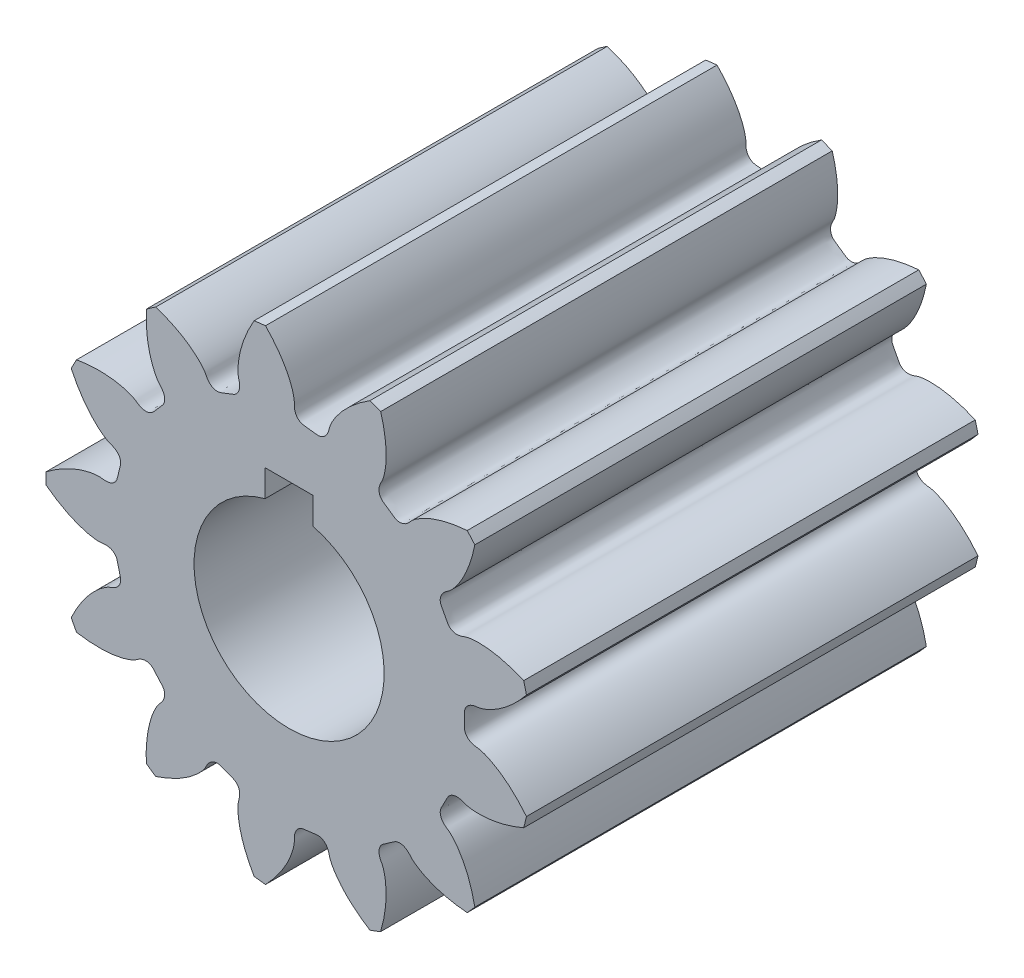
from build123d import *

# Parameters (mm, degrees)
BOSS_EXTRUDE1_DEPTH = 19.000000285


with BuildPart() as part:
    # Sketch1 → Boss-Extrude1 (new body)
    with BuildSketch(Plane.XY.offset(9.500000143)):
        with BuildLine():
            ThreePointArc((7.814726575, 6.600521756), (7.656677444, 6.783224114), (7.494357911, 6.962143228))
            add(Edge.make_bspline(
                [(3.852181327, 9.476156246), (3.919123652, 9.24993203), (3.98995363, 8.951615997), (4.045080446, 8.583763832), (4.066554173, 8.387248685), (4.079293934, 8.20275644), (4.084294989, 8.030651545), (4.082567712, 7.871237234), (4.07513333, 7.724756024), (4.063021014, 7.591389048), (4.047264207, 7.471256099), (4.028898477, 7.364414951), (4.008954757, 7.270863467), (3.988466837, 7.190533767), (3.968435849, 7.12331107), (3.949920357, 7.068981115), (3.933776349, 7.027377348), (3.910138888, 6.971704064), (3.877939068, 6.920721978), (3.850301468, 6.863364511), (3.833117776, 6.824070139), (3.818014359, 6.784105635), (3.804950881, 6.742844207), (3.79415029, 6.699282969), (3.786099872, 6.651977335), (3.781908634, 6.598855696), (3.783931909, 6.537201836), (3.79681493, 6.464228083), (3.828598855, 6.379850161), (3.886730558, 6.292619147), (4.013194901, 6.189835632), (4.1990099, 6.083315837), (4.364498543, 5.947348232), (4.505447672, 5.865549552), (4.607623873, 5.842128007), (4.697789335, 5.842330344), (4.770589362, 5.856161358), (4.828954186, 5.876132322), (4.877137548, 5.898888389), (4.918514367, 5.92319047), (4.95541489, 5.948736225), (4.989362623, 5.975582293), (5.021374338, 6.003875841), (5.052021794, 6.033876848), (5.09585153, 6.08005769), (5.132102395, 6.128243541), (5.175775862, 6.170086969), (5.208951315, 6.199934778), (5.253185023, 6.23651273), (5.308936251, 6.279079526), (5.376780709, 6.326721367), (5.457180727, 6.37854288), (5.550566359, 6.433601529), (5.657305178, 6.490934128), (5.777710381, 6.54955192), (5.912036424, 6.608446138), (6.060478894, 6.666590262), (6.223173166, 6.722943429), (6.400193993, 6.776453395), (6.591553537, 6.82606034), (6.955049526, 6.90495804), (7.259096519, 6.94451518), (7.494357911, 6.962143228)],
                knots=[0, 0, 0, 0, 0.096898989, 0.125710726, 0.152776298, 0.178095703, 0.201668943, 0.223496017, 0.243576925, 0.261911668, 0.278500244, 0.293342655, 0.3064389, 0.31778898, 0.327392894, 0.335250642, 0.341362226, 0.345727644, 0.360077399, 0.366027323, 0.371876298, 0.377692643, 0.383571459, 0.389647833, 0.396117153, 0.403264993, 0.41150466, 0.421398561, 0.433571282, 0.448324753, 0.463840247, 0.5, 0.536159753, 0.551675247, 0.566428718, 0.578601439, 0.58849534, 0.596735007, 0.603882847, 0.610352167, 0.616428541, 0.622307357, 0.628123702, 0.633972677, 0.639922601, 0.654272356, 0.658637774, 0.664749358, 0.672607106, 0.68221102, 0.6935611, 0.706657345, 0.721499756, 0.738088332, 0.756423075, 0.776503983, 0.798331057, 0.821904297, 0.847223702, 0.874289274, 0.903101011, 1.000000005, 1.000000005, 1.000000005, 1.000000005], degree=3))
            ThreePointArc((3.852181327, 9.476156246), (3.627329752, 9.564482056), (3.400455086, 9.647473416))
            add(Edge.make_bspline(
                [(-0.992852221, 10.180917536), (-0.828446101, 10.011715591), (-0.627094897, 9.780486193), (-0.4073331, 9.480387986), (-0.296993917, 9.316361804), (-0.199975598, 9.158922496), (-0.115566251, 9.008855286), (-0.043012155, 8.866898217), (0.01847824, 8.733740619), (0.06973204, 8.610021152), (0.111608646, 8.496326155), (0.144998157, 8.393188036), (0.170814413, 8.301084003), (0.190004333, 8.220434374), (0.203507719, 8.151602768), (0.212361454, 8.094891403), (0.217400879, 8.050550603), (0.222343612, 7.990269482), (0.217524644, 7.930163084), (0.219708109, 7.866531736), (0.22275371, 7.823752638), (0.22795273, 7.781346919), (0.235560737, 7.738740838), (0.246241205, 7.695149993), (0.261096938, 7.649521718), (0.282072637, 7.600537077), (0.312516136, 7.546885558), (0.357836078, 7.488257548), (0.425191722, 7.428315334), (0.517203063, 7.378091257), (0.676947558, 7.345851885), (0.890980785, 7.337885826), (1.100700998, 7.294398899), (1.263518996, 7.287472091), (1.364876063, 7.314216991), (1.444619585, 7.356298131), (1.502653214, 7.402376745), (1.54505173, 7.447183641), (1.577140706, 7.489725063), (1.60248432, 7.530472253), (1.623286406, 7.570240424), (1.640869641, 7.609787735), (1.65606594, 7.649717014), (1.669260751, 7.690524168), (1.686608747, 7.751783967), (1.696314213, 7.811297037), (1.715539536, 7.868643625), (1.731043973, 7.910489948), (1.753212354, 7.963434545), (1.782795839, 8.027034459), (1.820728855, 8.100748106), (1.867836877, 8.183997528), (1.924938718, 8.276148008), (1.992807461, 8.376517506), (2.072179927, 8.484376071), (2.163750223, 8.598948736), (2.268168582, 8.719417456), (2.386038583, 8.844923506), (2.51791542, 8.974569907), (2.664302384, 9.10742389), (2.949496508, 9.346209343), (3.200333631, 9.522533134), (3.400455086, 9.647473416)],
                knots=[0, 0, 0, 0, 0.096898989, 0.125710726, 0.152776298, 0.178095703, 0.201668943, 0.223496017, 0.243576925, 0.261911668, 0.278500244, 0.293342655, 0.3064389, 0.31778898, 0.327392894, 0.335250642, 0.341362226, 0.345727644, 0.360077399, 0.366027323, 0.371876298, 0.377692643, 0.383571459, 0.389647833, 0.396117153, 0.403264993, 0.41150466, 0.421398561, 0.433571282, 0.448324753, 0.463840247, 0.5, 0.536159753, 0.551675247, 0.566428718, 0.578601439, 0.58849534, 0.596735007, 0.603882847, 0.610352167, 0.616428541, 0.622307357, 0.628123702, 0.633972677, 0.639922601, 0.654272356, 0.658637774, 0.664749358, 0.672607106, 0.68221102, 0.6935611, 0.706657345, 0.721499756, 0.738088332, 0.756423075, 0.776503983, 0.798331057, 0.821904297, 0.847223702, 0.874289274, 0.903101011, 1.000000005, 1.000000005, 1.000000005, 1.000000005], degree=3))
            ThreePointArc((-0.992852221, 10.180917536), (-1.232995454, 10.15463242), (-1.472451002, 10.122683705))
            add(Edge.make_bspline(
                [(-5.610435273, 8.553353308), (-5.386228819, 8.479935759), (-5.100483523, 8.368764866), (-4.766431525, 8.2051695), (-4.592504263, 8.111208703), (-4.433433113, 8.016889781), (-4.288952638, 7.923238844), (-4.158738437, 7.831259673), (-4.042409975, 7.741930486), (-3.939531686, 7.656201167), (-3.849615093, 7.574990276), (-3.772119476, 7.499182886), (-3.706457438, 7.429626227), (-3.651985856, 7.367132529), (-3.608041559, 7.312460504), (-3.573846881, 7.266359621), (-3.548778494, 7.22943973), (-3.516387888, 7.17836045), (-3.492722036, 7.122899392), (-3.461217713, 7.067571338), (-3.438640528, 7.03110769), (-3.414330105, 6.995975395), (-3.387793516, 6.961785201), (-3.358078755, 6.928150885), (-3.323720141, 6.894652858), (-3.282382783, 6.861027006), (-3.2304933, 6.827668745), (-3.163118689, 6.796817447), (-3.075621693, 6.775042981), (-2.970809404, 6.773331572), (-2.814380295, 6.819021994), (-2.621161272, 6.911434599), (-2.415253863, 6.97039068), (-2.267866638, 7.039922592), (-2.190548387, 7.110707003), (-2.139495086, 7.185026664), (-2.109522659, 7.252796823), (-2.092803441, 7.312174932), (-2.084160048, 7.364755982), (-2.080655556, 7.412613591), (-2.080717414, 7.457493769), (-2.083526784, 7.50068251), (-2.088627191, 7.543100203), (-2.095907796, 7.585365079), (-2.109015757, 7.647669953), (-2.128079096, 7.704876514), (-2.137706205, 7.764588848), (-2.143424664, 7.808847199), (-2.14840012, 7.866029472), (-2.151761598, 7.936092529), (-2.15243002, 8.018991074), (-2.149405874, 8.114596966), (-2.141669168, 8.222728712), (-2.128218412, 8.343141666), (-2.108061958, 8.475531907), (-2.080225059, 8.619535802), (-2.043751801, 8.774731187), (-1.997708668, 8.940638196), (-1.941187215, 9.116720605), (-1.873308319, 9.302386379), (-1.731750597, 9.646356716), (-1.591587106, 9.919053502), (-1.472451002, 10.122683705)],
                knots=[0, 0, 0, 0, 0.096898989, 0.125710726, 0.152776298, 0.178095703, 0.201668943, 0.223496017, 0.243576925, 0.261911668, 0.278500244, 0.293342655, 0.3064389, 0.31778898, 0.327392894, 0.335250642, 0.341362226, 0.345727644, 0.360077399, 0.366027323, 0.371876298, 0.377692643, 0.383571459, 0.389647833, 0.396117153, 0.403264993, 0.41150466, 0.421398561, 0.433571282, 0.448324753, 0.463840247, 0.5, 0.536159753, 0.551675247, 0.566428718, 0.578601439, 0.58849534, 0.596735007, 0.603882847, 0.610352167, 0.616428541, 0.622307357, 0.628123702, 0.633972677, 0.639922601, 0.654272356, 0.658637774, 0.664749358, 0.672607106, 0.68221102, 0.6935611, 0.706657345, 0.721499756, 0.738088332, 0.756423075, 0.776503983, 0.798331057, 0.821904297, 0.847223702, 0.874289274, 0.903101011, 1.000000005, 1.000000005, 1.000000005, 1.000000005], degree=3))
            ThreePointArc((-5.610435273, 8.553353308), (-5.810856244, 8.418478868), (-6.008036293, 8.278909144))
            add(Edge.make_bspline(
                [(-8.9427352, 4.966318911), (-8.710091408, 5.005504835), (-8.405412824, 5.039860358), (-8.033597912, 5.05024556), (-7.83592721, 5.047875436), (-7.651244513, 5.038284226), (-7.479791646, 5.022503865), (-7.321747845, 5.00157391), (-7.177230764, 4.976537375), (-7.046296162, 4.948437758), (-6.92893839, 4.91831541), (-6.825089978, 4.887205308), (-6.73462454, 4.856130616), (-6.65735008, 4.8261094), (-6.59303198, 4.79812166), (-6.541329948, 4.773192415), (-6.501975465, 4.752151334), (-6.449557283, 4.721975544), (-6.402828173, 4.683865285), (-6.349220251, 4.649515516), (-6.312283644, 4.6277207), (-6.274431042, 4.607910215), (-6.235045084, 4.589968469), (-6.193103325, 4.573995899), (-6.147112972, 4.560302113), (-6.094883848, 4.549738328), (-6.033435635, 4.5443153), (-5.959441067, 4.548308376), (-5.871847226, 4.569689925), (-5.778245221, 4.616883246), (-5.660967522, 4.730036338), (-5.532826853, 4.901656993), (-5.377903154, 5.049549955), (-5.279711338, 5.179611664), (-5.244144582, 5.27821973), (-5.233477198, 5.367752174), (-5.238432295, 5.441688551), (-5.251222546, 5.502035064), (-5.268004834, 5.552610055), (-5.2871423, 5.596614483), (-5.308053932, 5.63632516), (-5.330612314, 5.673261311), (-5.354840985, 5.708450036), (-5.380929108, 5.742490259), (-5.421490149, 5.791566912), (-5.464955112, 5.833361631), (-5.5012292, 5.881760336), (-5.526860525, 5.918291659), (-5.557839999, 5.966611838), (-5.593376366, 6.027087437), (-5.632493099, 6.100179822), (-5.674245624, 6.186240026), (-5.717646439, 6.285581359), (-5.761695076, 6.398452612), (-5.805372235, 6.52504552), (-5.847645833, 6.665491088), (-5.887473258, 6.819859746), (-5.92380492, 6.988160417), (-5.955587234, 7.170340477), (-5.981766645, 7.36628425), (-6.016274493, 7.736640011), (-6.018894401, 8.043238246), (-6.008036293, 8.278909144)],
                knots=[0, 0, 0, 0, 0.096898989, 0.125710726, 0.152776298, 0.178095703, 0.201668943, 0.223496017, 0.243576925, 0.261911668, 0.278500244, 0.293342655, 0.3064389, 0.31778898, 0.327392894, 0.335250642, 0.341362226, 0.345727644, 0.360077399, 0.366027323, 0.371876298, 0.377692643, 0.383571459, 0.389647833, 0.396117153, 0.403264993, 0.41150466, 0.421398561, 0.433571282, 0.448324753, 0.463840247, 0.5, 0.536159753, 0.551675247, 0.566428718, 0.578601439, 0.58849534, 0.596735007, 0.603882847, 0.610352167, 0.616428541, 0.622307357, 0.628123702, 0.633972677, 0.639922601, 0.654272356, 0.658637774, 0.664749358, 0.672607106, 0.68221102, 0.6935611, 0.706657345, 0.721499756, 0.738088332, 0.756423075, 0.776503983, 0.798331057, 0.821904297, 0.847223702, 0.874289274, 0.903101011, 1.000000005, 1.000000005, 1.000000005, 1.000000005], degree=3))
            ThreePointArc((-8.9427352, 4.966318911), (-9.057519897, 4.753753222), (-9.167252891, 4.538536196))
            add(Edge.make_bspline(
                [(-10.226362249, 0.24156062), (-10.038577009, 0.384372995), (-9.78476333, 0.5563845), (-9.46036382, 0.738371147), (-9.284233655, 0.828134663), (-9.116247992, 0.905468399), (-8.957100519, 0.971173705), (-8.807433048, 1.026087768), (-8.66783447, 1.071079454), (-8.538839095, 1.107046824), (-8.420925396, 1.134913686), (-8.314514609, 1.155627823), (-8.219970312, 1.170153936), (-8.137595621, 1.179482703), (-8.067638221, 1.184590901), (-8.010273147, 1.186544283), (-7.965648205, 1.186202273), (-7.905210821, 1.183842882), (-7.846123529, 1.171814024), (-7.782692937, 1.166311658), (-7.73985864, 1.164178604), (-7.697135434, 1.164228272), (-7.653922956, 1.166645213), (-7.609362548, 1.171993513), (-7.562276294, 1.18124105), (-7.511120466, 1.196159368), (-7.454190569, 1.219913923), (-7.390527307, 1.257836607), (-7.322903315, 1.317475917), (-7.261954687, 1.402762549), (-7.210695307, 1.5574563), (-7.176988476, 1.768968782), (-7.10853964, 1.97191813), (-7.082037797, 2.132714066), (-7.096370453, 2.236555868), (-7.128532755, 2.32079029), (-7.167280224, 2.383954952), (-7.206649852, 2.431445209), (-7.2450132, 2.468428022), (-7.282408463, 2.498498383), (-7.319379265, 2.523942321), (-7.356518806, 2.546164256), (-7.394325244, 2.566062699), (-7.43324441, 2.584080064), (-7.491966487, 2.608685626), (-7.549875775, 2.625493835), (-7.604486884, 2.651491351), (-7.644159248, 2.67192676), (-7.694045717, 2.700315274), (-7.75361602, 2.737349184), (-7.822219893, 2.783890824), (-7.899184089, 2.840689984), (-7.983779822, 2.908483), (-8.075236841, 2.987955109), (-8.172741702, 3.079749773), (-8.275441425, 3.184462627), (-8.382445551, 3.302640556), (-8.492828863, 3.434779234), (-8.605634001, 3.581321686), (-8.719874331, 3.742655102), (-8.922542419, 4.054552244), (-9.067345539, 4.324813966), (-9.167252891, 4.538536196)],
                knots=[0, 0, 0, 0, 0.096898989, 0.125710726, 0.152776298, 0.178095703, 0.201668943, 0.223496017, 0.243576925, 0.261911668, 0.278500244, 0.293342655, 0.3064389, 0.31778898, 0.327392894, 0.335250642, 0.341362226, 0.345727644, 0.360077399, 0.366027323, 0.371876298, 0.377692643, 0.383571459, 0.389647833, 0.396117153, 0.403264993, 0.41150466, 0.421398561, 0.433571282, 0.448324753, 0.463840247, 0.5, 0.536159753, 0.551675247, 0.566428718, 0.578601439, 0.58849534, 0.596735007, 0.603882847, 0.610352167, 0.616428541, 0.622307357, 0.628123702, 0.633972677, 0.639922601, 0.654272356, 0.658637774, 0.664749358, 0.672607106, 0.68221102, 0.6935611, 0.706657345, 0.721499756, 0.738088332, 0.756423075, 0.776503983, 0.798331057, 0.821904297, 0.847223702, 0.874289274, 0.903101011, 1.000000005, 1.000000005, 1.000000005, 1.000000005], degree=3))
            ThreePointArc((-10.226362249, 0.24156062), (-10.229214847, 2e-08), (-10.22636225, -0.24156058))
            add(Edge.make_bspline(
                [(-9.167252926, -4.538536163), (-9.067345572, -4.324813934), (-8.922542451, -4.054552213), (-8.71987436, -3.742655073), (-8.605634029, -3.581321658), (-8.492828889, -3.434779207), (-8.382445577, -3.30264053), (-8.275441449, -3.184462601), (-8.172741726, -3.079749748), (-8.075236863, -2.987955085), (-7.983779844, -2.908482977), (-7.899184111, -2.840689961), (-7.822219914, -2.783890802), (-7.753616041, -2.737349162), (-7.694045737, -2.700315253), (-7.644159269, -2.671926739), (-7.604486905, -2.651491331), (-7.549875795, -2.625493815), (-7.491966507, -2.608685606), (-7.43324443, -2.584080044), (-7.394325264, -2.56606268), (-7.356518825, -2.546164237), (-7.319379284, -2.523942303), (-7.282408482, -2.498498365), (-7.245013219, -2.468428004), (-7.20664987, -2.431445191), (-7.167280242, -2.383954935), (-7.128532773, -2.320790273), (-7.09637047, -2.236555851), (-7.082037813, -2.132714049), (-7.108539656, -1.971918113), (-7.176988489, -1.768968765), (-7.210695318, -1.557456283), (-7.261954698, -1.402762531), (-7.322903325, -1.317475899), (-7.390527317, -1.257836588), (-7.454190578, -1.219913904), (-7.511120475, -1.196159348), (-7.562276303, -1.18124103), (-7.609362557, -1.171993492), (-7.653922965, -1.166645192), (-7.697135443, -1.164228251), (-7.739858649, -1.164178582), (-7.782692946, -1.166311636), (-7.846123538, -1.171814002), (-7.90521083, -1.183842859), (-7.965648214, -1.186202249), (-8.010273156, -1.18654426), (-8.06763823, -1.184590877), (-8.13759563, -1.179482678), (-8.219970321, -1.170153911), (-8.314514618, -1.155627797), (-8.420925405, -1.134913659), (-8.538839104, -1.107046796), (-8.667834478, -1.071079425), (-8.807433056, -1.026087738), (-8.957100526, -0.971173674), (-9.116247999, -0.905468367), (-9.284233662, -0.82813463), (-9.460363826, -0.738371112), (-9.784763334, -0.556384463), (-10.038577012, -0.384372956), (-10.22636225, -0.24156058)],
                knots=[0, 0, 0, 0, 0.096898989, 0.125710726, 0.152776298, 0.178095703, 0.201668943, 0.223496017, 0.243576925, 0.261911668, 0.278500244, 0.293342655, 0.3064389, 0.31778898, 0.327392894, 0.335250642, 0.341362226, 0.345727644, 0.360077399, 0.366027323, 0.371876298, 0.377692643, 0.383571459, 0.389647833, 0.396117153, 0.403264993, 0.41150466, 0.421398561, 0.433571282, 0.448324753, 0.463840247, 0.5, 0.536159753, 0.551675247, 0.566428718, 0.578601439, 0.58849534, 0.596735007, 0.603882847, 0.610352167, 0.616428541, 0.622307357, 0.628123702, 0.633972677, 0.639922601, 0.654272356, 0.658637774, 0.664749358, 0.672607106, 0.68221102, 0.6935611, 0.706657345, 0.721499756, 0.738088332, 0.756423075, 0.776503983, 0.798331057, 0.821904297, 0.847223702, 0.874289274, 0.903101011, 1.000000005, 1.000000005, 1.000000005, 1.000000005], degree=3))
            ThreePointArc((-9.167252926, -4.538536163), (-9.057519951, -4.753753156), (-8.942735276, -4.966318812))
            add(Edge.make_bspline(
                [(-6.00803642, -8.27890909), (-6.018894524, -8.043238192), (-6.016274611, -7.736639957), (-5.981766758, -7.366284196), (-5.955587344, -7.170340423), (-5.923805027, -6.988160364), (-5.887473362, -6.819859693), (-5.847645935, -6.665491037), (-5.805372335, -6.525045469), (-5.761695174, -6.398452562), (-5.717646535, -6.285581309), (-5.674245719, -6.186239977), (-5.632493193, -6.100179774), (-5.593376459, -6.027087389), (-5.55784009, -5.96661179), (-5.526860616, -5.918291612), (-5.50122929, -5.88176029), (-5.464955201, -5.833361585), (-5.421490238, -5.791566866), (-5.380929196, -5.742490214), (-5.354841072, -5.708449992), (-5.330612401, -5.673261267), (-5.308054018, -5.636325116), (-5.287142386, -5.59661444), (-5.268004919, -5.552610012), (-5.25122263, -5.502035021), (-5.238432379, -5.441688508), (-5.23347728, -5.367752132), (-5.244144663, -5.278219687), (-5.279711417, -5.179611621), (-5.377903231, -5.04954991), (-5.532826928, -4.901656946), (-5.660967595, -4.730036289), (-5.778245292, -4.616883195), (-5.871847296, -4.569689872), (-5.959441136, -4.548308322), (-6.033435705, -4.544315245), (-6.094883918, -4.549738273), (-6.147113042, -4.560302057), (-6.193103395, -4.573995842), (-6.235045155, -4.589968411), (-6.274431113, -4.607910156), (-6.312283715, -4.627720641), (-6.349220322, -4.649515457), (-6.402828244, -4.683865225), (-6.449557355, -4.721975483), (-6.501975538, -4.752151273), (-6.541330021, -4.773192352), (-6.593032054, -4.798121597), (-6.657350154, -4.826109336), (-6.734624614, -4.856130551), (-6.825090053, -4.887205241), (-6.928938466, -4.918315341), (-7.046296238, -4.948437688), (-7.17723084, -4.976537302), (-7.321747921, -5.001573835), (-7.479791723, -5.022503788), (-7.651244591, -5.038284147), (-7.835927287, -5.047875353), (-8.033597989, -5.050245474), (-8.405412901, -5.039860267), (-8.710091485, -5.00550474), (-8.942735276, -4.966318812)],
                knots=[0, 0, 0, 0, 0.096898989, 0.125710726, 0.152776298, 0.178095703, 0.201668943, 0.223496017, 0.243576925, 0.261911668, 0.278500244, 0.293342655, 0.3064389, 0.31778898, 0.327392894, 0.335250642, 0.341362226, 0.345727644, 0.360077399, 0.366027323, 0.371876298, 0.377692643, 0.383571459, 0.389647833, 0.396117153, 0.403264993, 0.41150466, 0.421398561, 0.433571282, 0.448324753, 0.463840247, 0.5, 0.536159753, 0.551675247, 0.566428718, 0.578601439, 0.58849534, 0.596735007, 0.603882847, 0.610352167, 0.616428541, 0.622307357, 0.628123702, 0.633972677, 0.639922601, 0.654272356, 0.658637774, 0.664749358, 0.672607106, 0.68221102, 0.6935611, 0.706657345, 0.721499756, 0.738088332, 0.756423075, 0.776503983, 0.798331057, 0.821904297, 0.847223702, 0.874289274, 0.903101011, 1.000000005, 1.000000005, 1.000000005, 1.000000005], degree=3))
            ThreePointArc((-6.00803642, -8.27890909), (-5.810856373, -8.418478817), (-5.610435404, -8.553353259))
            add(Edge.make_bspline(
                [(-1.472451157, -10.12268372), (-1.591587258, -9.919053515), (-1.731750745, -9.646356727), (-1.873308462, -9.302386388), (-1.941187354, -9.116720613), (-1.997708805, -8.940638203), (-2.043751935, -8.774731193), (-2.080225191, -8.619535808), (-2.108062087, -8.475531912), (-2.12821854, -8.343141671), (-2.141669293, -8.222728717), (-2.149405998, -8.114596971), (-2.152430142, -8.018991079), (-2.151761719, -7.936092534), (-2.14840024, -7.866029476), (-2.143424784, -7.808847204), (-2.137706324, -7.764588853), (-2.128079214, -7.704876519), (-2.109015874, -7.647669958), (-2.095907912, -7.585365084), (-2.088627306, -7.543100209), (-2.083526899, -7.500682516), (-2.080717528, -7.457493775), (-2.080655669, -7.412613597), (-2.08416016, -7.364755987), (-2.092803553, -7.312174938), (-2.10952277, -7.252796829), (-2.139495196, -7.185026669), (-2.190548496, -7.110707007), (-2.267866746, -7.039922595), (-2.41525397, -6.970390681), (-2.621161378, -6.911434597), (-2.8143804, -6.819021989), (-2.970809508, -6.773331564), (-3.075621797, -6.775042972), (-3.163118793, -6.796817436), (-3.230493405, -6.827668733), (-3.282382889, -6.861026994), (-3.323720246, -6.894652845), (-3.358078862, -6.928150872), (-3.387793623, -6.961785187), (-3.414330212, -6.995975381), (-3.438640636, -7.031107675), (-3.461217821, -7.067571323), (-3.492722145, -7.122899376), (-3.516387998, -7.178360434), (-3.548778605, -7.229439713), (-3.573846992, -7.266359604), (-3.608041671, -7.312460487), (-3.651985969, -7.367132511), (-3.706457552, -7.429626208), (-3.772119591, -7.499182866), (-3.849615209, -7.574990255), (-3.939531803, -7.656201145), (-4.042410094, -7.741930461), (-4.158738557, -7.831259647), (-4.28895276, -7.923238816), (-4.433433236, -8.016889751), (-4.592504387, -8.111208671), (-4.766431651, -8.205169464), (-5.100483652, -8.368764825), (-5.386228949, -8.479935714), (-5.610435404, -8.553353259)],
                knots=[0, 0, 0, 0, 0.096898989, 0.125710726, 0.152776298, 0.178095703, 0.201668943, 0.223496017, 0.243576925, 0.261911668, 0.278500244, 0.293342655, 0.3064389, 0.31778898, 0.327392894, 0.335250642, 0.341362226, 0.345727644, 0.360077399, 0.366027323, 0.371876298, 0.377692643, 0.383571459, 0.389647833, 0.396117153, 0.403264993, 0.41150466, 0.421398561, 0.433571282, 0.448324753, 0.463840247, 0.5, 0.536159753, 0.551675247, 0.566428718, 0.578601439, 0.58849534, 0.596735007, 0.603882847, 0.610352167, 0.616428541, 0.622307357, 0.628123702, 0.633972677, 0.639922601, 0.654272356, 0.658637774, 0.664749358, 0.672607106, 0.68221102, 0.6935611, 0.706657345, 0.721499756, 0.738088332, 0.756423075, 0.776503983, 0.798331057, 0.821904297, 0.847223702, 0.874289274, 0.903101011, 1.000000005, 1.000000005, 1.000000005, 1.000000005], degree=3))
            ThreePointArc((-1.472451157, -10.12268372), (-1.23299561, -10.154632439), (-0.992852377, -10.180917559))
            add(Edge.make_bspline(
                [(3.400454938, -9.647473506), (3.200333485, -9.522533221), (2.949496365, -9.346209426), (2.664302244, -9.107423968), (2.517915282, -8.974569984), (2.386038447, -8.84492358), (2.268168448, -8.719417529), (2.163750092, -8.598948807), (2.072179797, -8.48437614), (1.992807333, -8.376517574), (1.924938591, -8.276148075), (1.867836752, -8.183997595), (1.820728731, -8.100748171), (1.782795716, -8.027034524), (1.753212232, -7.96343461), (1.731043852, -7.910490012), (1.715539416, -7.868643688), (1.696314093, -7.811297101), (1.686608628, -7.751784031), (1.669260633, -7.690524232), (1.656065822, -7.649717077), (1.640869524, -7.609787797), (1.62328629, -7.570240487), (1.602484205, -7.530472316), (1.577140591, -7.489725125), (1.545051616, -7.447183703), (1.502653101, -7.402376805), (1.444619472, -7.35629819), (1.364875951, -7.314217049), (1.263518884, -7.287472148), (1.100700887, -7.294398953), (0.890980673, -7.337885877), (0.676947445, -7.345851933), (0.51720295, -7.378091303), (0.425191608, -7.428315378), (0.357835964, -7.488257591), (0.31251602, -7.546885601), (0.282072521, -7.600537119), (0.26109682, -7.649521759), (0.246241087, -7.695150034), (0.235560618, -7.738740879), (0.227952611, -7.78134696), (0.222753591, -7.823752679), (0.219707988, -7.866531777), (0.217524523, -7.930163125), (0.22234349, -7.990269523), (0.217400756, -8.050550644), (0.21236133, -8.094891444), (0.203507594, -8.151602808), (0.190004207, -8.220434415), (0.170814285, -8.301084043), (0.144998028, -8.393188076), (0.111608516, -8.496326195), (0.069731909, -8.610021191), (0.018478106, -8.733740657), (-0.04301229, -8.866898254), (-0.115566389, -9.008855321), (-0.199975738, -9.158922531), (-0.29699406, -9.316361837), (-0.407333245, -9.480388017), (-0.627095047, -9.780486221), (-0.828446254, -10.011715616), (-0.992852377, -10.180917559)],
                knots=[0, 0, 0, 0, 0.096898989, 0.125710726, 0.152776298, 0.178095703, 0.201668943, 0.223496017, 0.243576925, 0.261911668, 0.278500244, 0.293342655, 0.3064389, 0.31778898, 0.327392894, 0.335250642, 0.341362226, 0.345727644, 0.360077399, 0.366027323, 0.371876298, 0.377692643, 0.383571459, 0.389647833, 0.396117153, 0.403264993, 0.41150466, 0.421398561, 0.433571282, 0.448324753, 0.463840247, 0.5, 0.536159753, 0.551675247, 0.566428718, 0.578601439, 0.58849534, 0.596735007, 0.603882847, 0.610352167, 0.616428541, 0.622307357, 0.628123702, 0.633972677, 0.639922601, 0.654272356, 0.658637774, 0.664749358, 0.672607106, 0.68221102, 0.6935611, 0.706657345, 0.721499756, 0.738088332, 0.756423075, 0.776503983, 0.798331057, 0.821904297, 0.847223702, 0.874289274, 0.903101011, 1.000000005, 1.000000005, 1.000000005, 1.000000005], degree=3))
            ThreePointArc((3.400454938, -9.647473506), (3.627329605, -9.56448215), (3.852181182, -9.476156343))
            add(Edge.make_bspline(
                [(7.494357805, -6.96214338), (7.259096413, -6.944515329), (6.95504942, -6.904958185), (6.591553432, -6.826060478), (6.400193889, -6.77645353), (6.223173063, -6.722943562), (6.060478792, -6.666590392), (5.912036322, -6.608446267), (5.777710281, -6.549552046), (5.657305078, -6.490934252), (5.55056626, -6.433601652), (5.457180629, -6.378543002), (5.376780612, -6.326721487), (5.308936155, -6.279079645), (5.253184927, -6.236512848), (5.20895122, -6.199934895), (5.175775767, -6.170087086), (5.132102302, -6.128243657), (5.095851436, -6.080057806), (5.052021701, -6.033876963), (5.021374247, -6.003875956), (4.989362531, -5.975582407), (4.955414799, -5.948736339), (4.918514276, -5.923190583), (4.877137458, -5.898888502), (4.828954096, -5.876132434), (4.770589272, -5.856161469), (4.697789246, -5.842330453), (4.607623783, -5.842128115), (4.505447582, -5.865549659), (4.364498452, -5.947348337), (4.199009807, -6.083315939), (4.013194806, -6.189835732), (3.886730462, -6.292619244), (3.828598757, -6.379850257), (3.796814831, -6.464228179), (3.783931809, -6.537201932), (3.781908533, -6.598855791), (3.78609977, -6.65197743), (3.794150187, -6.699283065), (3.804950778, -6.742844303), (3.818014255, -6.784105731), (3.833117671, -6.824070236), (3.850301363, -6.863364608), (3.877938962, -6.920722075), (3.910138781, -6.971704162), (3.933776241, -7.027377446), (3.949920249, -7.068981213), (3.96843574, -7.123311168), (3.988466727, -7.190533866), (4.008954646, -7.270863566), (4.028898364, -7.36441505), (4.047264093, -7.471256199), (4.063020898, -7.591389148), (4.075133212, -7.724756125), (4.082567591, -7.871237334), (4.084294866, -8.030651645), (4.079293808, -8.202756541), (4.066554045, -8.387248785), (4.045080315, -8.583763931), (3.989953492, -8.951616095), (3.91912351, -9.249932128), (3.852181182, -9.476156343)],
                knots=[0, 0, 0, 0, 0.096898989, 0.125710726, 0.152776298, 0.178095703, 0.201668943, 0.223496017, 0.243576925, 0.261911668, 0.278500244, 0.293342655, 0.3064389, 0.31778898, 0.327392894, 0.335250642, 0.341362226, 0.345727644, 0.360077399, 0.366027323, 0.371876298, 0.377692643, 0.383571459, 0.389647833, 0.396117153, 0.403264993, 0.41150466, 0.421398561, 0.433571282, 0.448324753, 0.463840247, 0.5, 0.536159753, 0.551675247, 0.566428718, 0.578601439, 0.58849534, 0.596735007, 0.603882847, 0.610352167, 0.616428541, 0.622307357, 0.628123702, 0.633972677, 0.639922601, 0.654272356, 0.658637774, 0.664749358, 0.672607106, 0.68221102, 0.6935611, 0.706657345, 0.721499756, 0.738088332, 0.756423075, 0.776503983, 0.798331057, 0.821904297, 0.847223702, 0.874289274, 0.903101011, 1.000000005, 1.000000005, 1.000000005, 1.000000005], degree=3))
            ThreePointArc((7.494357805, -6.96214338), (7.65667734, -6.783224269), (7.814726474, -6.600521913))
            add(Edge.make_bspline(
                [(9.871393632, -2.681870114), (9.654887851, -2.775592669), (9.367284488, -2.881864241), (9.008759183, -2.9809288), (8.816265225, -3.025933243), (8.634653745, -3.060818199), (8.464406499, -3.086527743), (8.305946297, -3.104028332), (8.159636985, -3.114304514), (8.025782426, -3.118356123), (7.904626108, -3.117194628), (7.796350208, -3.111841081), (7.70107687, -3.103319159), (7.618863318, -3.092663294), (7.549716281, -3.080881156), (7.493550656, -3.069049415), (7.450304283, -3.058037895), (7.392187739, -3.04128345), (7.33769611, -3.015463614), (7.277425499, -2.994941202), (7.236346362, -2.982619212), (7.194852728, -2.972443104), (7.152317514, -2.96444839), (7.10777202, -2.958977274), (7.059840926, -2.956687616), (7.006601406, -2.958930043), (6.945640951, -2.968370118), (6.874752135, -2.989955221), (6.794820552, -3.03167804), (6.715232553, -3.099900435), (6.628442038, -3.237831894), (6.545096415, -3.435131635), (6.430067619, -3.615802764), (6.365854883, -3.765583955), (6.354920088, -3.869838332), (6.365989195, -3.959321998), (6.388494439, -4.029924086), (6.415354894, -4.085456131), (6.443752907, -4.130545241), (6.472865222, -4.168691085), (6.502672586, -4.202243361), (6.533414863, -4.23270764), (6.565360705, -4.261075544), (6.598837113, -4.287883323), (6.649964336, -4.325827006), (6.702168417, -4.356005399), (6.748971014, -4.394316769), (6.782600058, -4.42365258), (6.8242431, -4.463154789), (6.873219603, -4.513368668), (6.928691828, -4.574975874), (6.989826655, -4.648543292), (7.055740258, -4.734611451), (7.125520781, -4.833661342), (7.198224427, -4.946123062), (7.272880455, -5.072370803), (7.348493406, -5.212722461), (7.424046322, -5.367437885), (7.498503643, -5.536718118), (7.570814741, -5.720702978), (7.692951789, -6.072038605), (7.768869327, -6.369100668), (7.814726474, -6.600521913)],
                knots=[0, 0, 0, 0, 0.096898989, 0.125710726, 0.152776298, 0.178095703, 0.201668943, 0.223496017, 0.243576925, 0.261911668, 0.278500244, 0.293342655, 0.3064389, 0.31778898, 0.327392894, 0.335250642, 0.341362226, 0.345727644, 0.360077399, 0.366027323, 0.371876298, 0.377692643, 0.383571459, 0.389647833, 0.396117153, 0.403264993, 0.41150466, 0.421398561, 0.433571282, 0.448324753, 0.463840247, 0.5, 0.536159753, 0.551675247, 0.566428718, 0.578601439, 0.58849534, 0.596735007, 0.603882847, 0.610352167, 0.616428541, 0.622307357, 0.628123702, 0.633972677, 0.639922601, 0.654272356, 0.658637774, 0.664749358, 0.672607106, 0.68221102, 0.6935611, 0.706657345, 0.721499756, 0.738088332, 0.756423075, 0.776503983, 0.798331057, 0.821904297, 0.847223702, 0.874289274, 0.903101011, 1.000000005, 1.000000005, 1.000000005, 1.000000005], degree=3))
            ThreePointArc((9.871393632, -2.681870114), (9.931972593, -2.44801143), (9.987012139, -2.212787402))
            add(Edge.make_bspline(
                [(9.987012146, 2.212787331), (9.838860843, 2.029184876), (9.633587575, 1.801430124), (9.362166781, 1.547097794), (9.212636453, 1.417791935), (9.068039322, 1.302503777), (8.929240694, 1.200621265), (8.797064083, 1.111485135), (8.672289202, 1.034392699), (8.555649752, 0.968599862), (8.447831388, 0.913324166), (8.349469922, 0.867746175), (8.261149237, 0.831016234), (8.183400725, 0.802244991), (8.116698632, 0.780543325), (8.061467957, 0.764918344), (8.018057887, 0.754570969), (7.958812064, 0.742398188), (7.898563046, 0.739936994), (7.835658831, 0.730099538), (7.793558747, 0.721919691), (7.752088886, 0.711647133), (7.710710495, 0.698959002), (7.668724864, 0.68310211), (7.625219932, 0.662854811), (7.579120786, 0.636127602), (7.529530005, 0.599439095), (7.476792175, 0.547382759), (7.425405834, 0.473292979), (7.386638689, 0.37589866), (7.37388945, 0.213432855), (7.391780329, -3.1e-08), (7.37388945, -0.213432918), (7.386638687, -0.375898723), (7.425405832, -0.473293041), (7.476792173, -0.547382822), (7.529530003, -0.599439157), (7.579120784, -0.636127665), (7.62521993, -0.662854874), (7.668724862, -0.683102174), (7.710710493, -0.698959065), (7.752088884, -0.711647197), (7.793558745, -0.721919755), (7.835658828, -0.730099601), (7.898563044, -0.739937058), (7.958812061, -0.742398252), (8.018057884, -0.754571033), (8.061467954, -0.764918409), (8.116698629, -0.78054339), (8.183400722, -0.802245055), (8.261149234, -0.831016299), (8.349469919, -0.867746241), (8.447831385, -0.913324231), (8.555649749, -0.968599928), (8.672289198, -1.034392766), (8.797064079, -1.111485202), (8.92924069, -1.200621332), (9.068039318, -1.302503845), (9.212636449, -1.417792004), (9.362166775, -1.547097863), (9.633587569, -1.801430193), (9.838860836, -2.029184946), (9.987012139, -2.212787402)],
                knots=[0, 0, 0, 0, 0.096898989, 0.125710726, 0.152776298, 0.178095703, 0.201668943, 0.223496017, 0.243576925, 0.261911668, 0.278500244, 0.293342655, 0.3064389, 0.31778898, 0.327392894, 0.335250642, 0.341362226, 0.345727644, 0.360077399, 0.366027323, 0.371876298, 0.377692643, 0.383571459, 0.389647833, 0.396117153, 0.403264993, 0.41150466, 0.421398561, 0.433571282, 0.448324753, 0.463840247, 0.5, 0.536159753, 0.551675247, 0.566428718, 0.578601439, 0.58849534, 0.596735007, 0.603882847, 0.610352167, 0.616428541, 0.622307357, 0.628123702, 0.633972677, 0.639922601, 0.654272356, 0.658637774, 0.664749358, 0.672607106, 0.68221102, 0.6935611, 0.706657345, 0.721499756, 0.738088332, 0.756423075, 0.776503983, 0.798331057, 0.821904297, 0.847223702, 0.874289274, 0.903101011, 1, 1, 1, 1], degree=3))
            ThreePointArc((9.987012146, 2.212787331), (9.931972616, 2.448011299), (9.871393674, 2.681869925))
            add(Edge.make_bspline(
                [(7.814726575, 6.600521756), (7.768869425, 6.369100511), (7.692951882, 6.07203845), (7.570814829, 5.720702824), (7.498503727, 5.536717965), (7.424046404, 5.367437734), (7.348493485, 5.212722311), (7.272880533, 5.072370654), (7.198224503, 4.946122914), (7.125520855, 4.833661196), (7.055740331, 4.734611305), (6.989826727, 4.648543147), (6.928691898, 4.574975731), (6.873219673, 4.513368525), (6.824243168, 4.463154647), (6.782600125, 4.423652439), (6.748971082, 4.394316628), (6.702168484, 4.356005259), (6.649964402, 4.325826866), (6.598837179, 4.287883184), (6.565360771, 4.261075406), (6.533414928, 4.232707503), (6.502672651, 4.202243223), (6.472865286, 4.168690948), (6.44375297, 4.130545105), (6.415354956, 4.085455995), (6.3884945, 4.02992395), (6.365989255, 3.959321863), (6.354920147, 3.869838197), (6.365854941, 3.76558382), (6.430067674, 3.615802627), (6.545096467, 3.435131497), (6.628442088, 3.237831755), (6.7152326, 3.099900295), (6.794820598, 3.031677898), (6.874752181, 2.989955079), (6.945640996, 2.968369974), (7.006601451, 2.958929898), (7.059840971, 2.956687471), (7.107772065, 2.958977128), (7.15231756, 2.964448242), (7.194852774, 2.972442957), (7.236346408, 2.982619063), (7.277425545, 2.994941053), (7.337696156, 3.015463464), (7.392187785, 3.041283299), (7.45030433, 3.058037743), (7.493550703, 3.069049263), (7.549716328, 3.080881002), (7.618863365, 3.09266314), (7.701076917, 3.103319004), (7.796350255, 3.111840924), (7.904626156, 3.117194469), (8.025782473, 3.118355962), (8.159637033, 3.114304351), (8.305946344, 3.104028167), (8.464406546, 3.086527576), (8.634653792, 3.060818029), (8.816265271, 3.02593307), (9.008759229, 2.980928624), (9.367284532, 2.88186406), (9.654887894, 2.775592484), (9.871393674, 2.681869925)],
                knots=[0, 0, 0, 0, 0.096898989, 0.125710726, 0.152776298, 0.178095703, 0.201668943, 0.223496017, 0.243576925, 0.261911668, 0.278500244, 0.293342655, 0.3064389, 0.31778898, 0.327392894, 0.335250642, 0.341362226, 0.345727644, 0.360077399, 0.366027323, 0.371876298, 0.377692643, 0.383571459, 0.389647833, 0.396117153, 0.403264993, 0.41150466, 0.421398561, 0.433571282, 0.448324753, 0.463840247, 0.5, 0.536159753, 0.551675247, 0.566428718, 0.578601439, 0.58849534, 0.596735007, 0.603882847, 0.610352167, 0.616428541, 0.622307357, 0.628123702, 0.633972677, 0.639922601, 0.654272356, 0.658637774, 0.664749358, 0.672607106, 0.68221102, 0.6935611, 0.706657345, 0.721499756, 0.738088332, 0.756423075, 0.776503983, 0.798331057, 0.821904297, 0.847223702, 0.874289274, 0.903101011, 1.000000005, 1.000000005, 1.000000005, 1.000000005], degree=3))
        make_face()
        with BuildLine():
            Line((1.010000076, 4.999999981), (1.010000076, 3.870387559))
            ThreePointArc((1.010000076, 3.870387559), (7.6e-08, -4.000000019), (-1.009999924, 3.870387559))
            Line((-1.009999924, 3.870387559), (-1.009999924, 4.999999981))
            Line((-1.009999924, 4.999999981), (1.010000076, 4.999999981))
        make_face(mode=Mode.SUBTRACT)
    extrude(amount=-BOSS_EXTRUDE1_DEPTH)


solid = part.part
